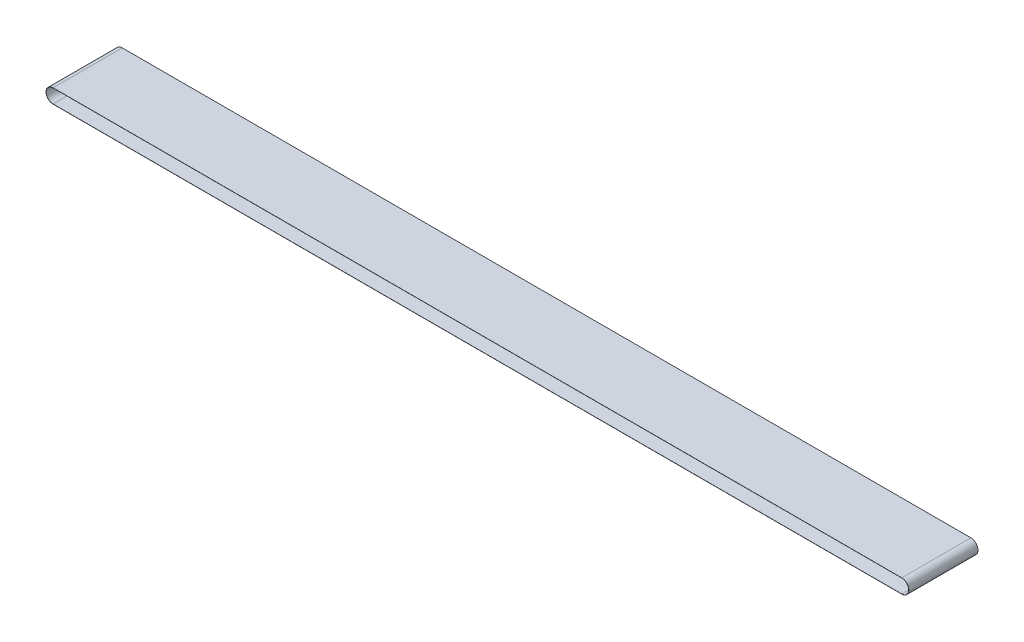
from build123d import *

# Parameters (mm, degrees)
BOSS_EXTRUDE1_DEPTH = 250


with BuildPart() as part:
    # Sketch1 → Boss-Extrude1 (new body, symmetric)
    with BuildSketch(Plane.XY):
        with BuildLine():
            Line((0, -51.2), (6134.96, -51.2))
            ThreePointArc((6134.96, -51.2), (6186.16, 0), (6134.96, 51.2))
            Line((6134.96, 51.2), (0, 51.2))
            ThreePointArc((0, 51.2), (-51.2, 0), (0, -51.2))
        make_face()
        with BuildLine():
            Line((0, 50), (6134.96, 50))
            ThreePointArc((6134.96, 50), (6184.96, 0), (6134.96, -50))
            Line((6134.96, -50), (0, -50))
            ThreePointArc((0, -50), (-50, 0), (0, 50))
        make_face(mode=Mode.SUBTRACT)
    extrude(amount=BOSS_EXTRUDE1_DEPTH, both=True)


solid = part.part
